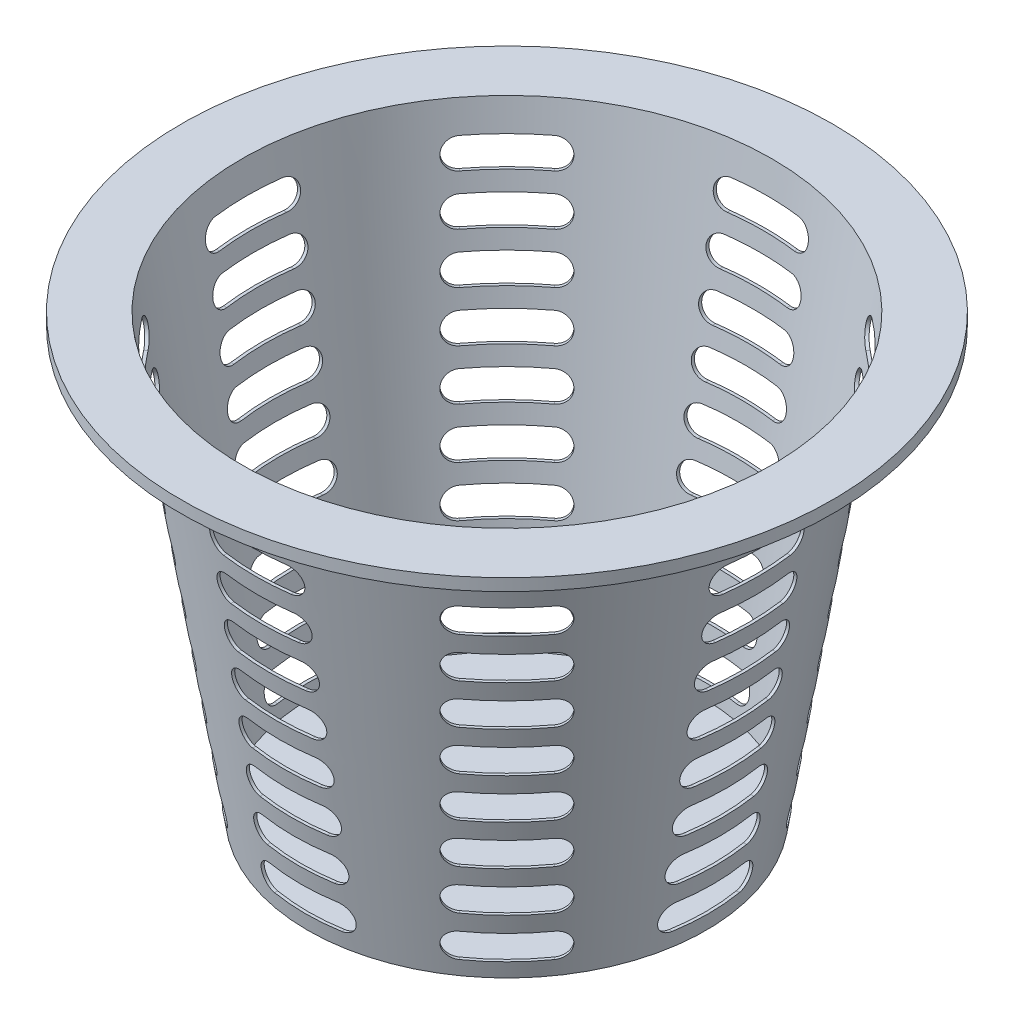
from build123d import *

# Parameters (mm, degrees)
THICKEN1_T2               = 2
CUT_EXTRUDE1_DEPTH        = 190
LPATTERN1_COUNT           = 9
LPATTERN1_PITCH           = 30
CIRPATTERN2_COUNT         = 8
CIRPATTERN2_COPY_1_DEPTH  = 190
CIRPATTERN2_COPY_2_DEPTH  = 190
CIRPATTERN2_COPY_3_DEPTH  = 190
CIRPATTERN2_COPY_4_DEPTH  = 190
CIRPATTERN2_COPY_5_DEPTH  = 190
CIRPATTERN2_COPY_6_DEPTH  = 190
CIRPATTERN2_COPY_7_DEPTH  = 190
CIRPATTERN2_COPY_8_DEPTH  = 190
CIRPATTERN2_COPY_9_DEPTH  = 190
CIRPATTERN2_COPY_10_DEPTH = 190
CIRPATTERN2_COPY_11_DEPTH = 190
CIRPATTERN2_COPY_12_DEPTH = 190
CIRPATTERN2_COPY_13_DEPTH = 190
CIRPATTERN2_COPY_14_DEPTH = 190
CIRPATTERN2_COPY_15_DEPTH = 190
CIRPATTERN2_COPY_16_DEPTH = 190
CIRPATTERN2_COPY_17_DEPTH = 190
CIRPATTERN2_COPY_18_DEPTH = 190
CIRPATTERN2_COPY_19_DEPTH = 190
CIRPATTERN2_COPY_20_DEPTH = 190
CIRPATTERN2_COPY_21_DEPTH = 190
CIRPATTERN2_COPY_22_DEPTH = 190
CIRPATTERN2_COPY_23_DEPTH = 190
CIRPATTERN2_COPY_24_DEPTH = 190
CIRPATTERN2_COPY_25_DEPTH = 190
CIRPATTERN2_COPY_26_DEPTH = 190
CIRPATTERN2_COPY_27_DEPTH = 190
CIRPATTERN2_COPY_28_DEPTH = 190
CIRPATTERN2_COPY_29_DEPTH = 190
CIRPATTERN2_COPY_30_DEPTH = 190
CIRPATTERN2_COPY_31_DEPTH = 190
CIRPATTERN2_COPY_32_DEPTH = 190
CIRPATTERN2_COPY_33_DEPTH = 190
CIRPATTERN2_COPY_34_DEPTH = 190
CIRPATTERN2_COPY_35_DEPTH = 190
CIRPATTERN2_COPY_36_DEPTH = 190
CIRPATTERN2_COPY_37_DEPTH = 190
CIRPATTERN2_COPY_38_DEPTH = 190
CIRPATTERN2_COPY_39_DEPTH = 190
CIRPATTERN2_COPY_40_DEPTH = 190
CIRPATTERN2_COPY_41_DEPTH = 190
CIRPATTERN2_COPY_42_DEPTH = 190
CIRPATTERN2_COPY_43_DEPTH = 190
CIRPATTERN2_COPY_44_DEPTH = 190
CIRPATTERN2_COPY_45_DEPTH = 190
CIRPATTERN2_COPY_46_DEPTH = 190
CIRPATTERN2_COPY_47_DEPTH = 190
CIRPATTERN2_COPY_48_DEPTH = 190
CIRPATTERN2_COPY_49_DEPTH = 190
CIRPATTERN2_COPY_50_DEPTH = 190
CIRPATTERN2_COPY_51_DEPTH = 190
CIRPATTERN2_COPY_52_DEPTH = 190
CIRPATTERN2_COPY_53_DEPTH = 190
CIRPATTERN2_COPY_54_DEPTH = 190
CIRPATTERN2_COPY_55_DEPTH = 190
CIRPATTERN2_COPY_56_DEPTH = 190


with BuildPart() as body_1:
    # Surface-Revolve1: a surface, the sketch's curves turned about an axis
    with BuildLine(Plane.XY, mode=Mode.PRIVATE) as surface_revolve1_1_path:
        Line((0, -120.209059233), (130, -120.209059233))
        Line((130, -120.209059233), (175.365994862, 166.220559539))
        Line((175.365994862, 166.220559539), (215.365994862, 166.220559539))
        Line((215.365994862, 166.220559539), (215.365994862, 158.220559539))
    surface_revolve1_1 = Shell.revolve(surface_revolve1_1_path.wire(), 360, Axis((0, 129.790940767, 0), (0, -1, 0)))
    add(Solid.thicken(surface_revolve1_1, -THICKEN1_T2))

    # Sketch2 → Cut-Extrude1 (cut)
    with BuildSketch(Plane.XY):
        with BuildLine():
            Line((22.22432483, -111.75560677), (-22.22432483, -111.75560677))
            ThreePointArc((-22.22432483, -111.75560677), (-31.363299527, -102.616632073), (-22.22432483, -93.477657376))
            Line((-22.22432483, -93.477657376), (22.22432483, -93.477657376))
            ThreePointArc((22.22432483, -93.477657376), (31.363299527, -102.616632073), (22.22432483, -111.75560677))
        make_face()
    cut_extrude1 = extrude(amount=-CUT_EXTRUDE1_DEPTH, mode=Mode.SUBTRACT)

    # LPattern1: Cut-Extrude1 ×9
    with Locations(*[(0, i * LPATTERN1_PITCH, 0) for i in range(1, LPATTERN1_COUNT)]):
        add(cut_extrude1, mode=Mode.SUBTRACT)

    # CirPattern2: Cut-Extrude1 ×8 about axis
    cirpattern2_axis = Axis((0, -120.521928164, 0), (0, 1, 0))
    for i in range(1, CIRPATTERN2_COUNT):
        add(cut_extrude1.rotate(cirpattern2_axis, i * 360 / CIRPATTERN2_COUNT), mode=Mode.SUBTRACT)

    # CirPattern2 copy 1 sketch → CirPattern2 copy 1 (cut)
    with BuildSketch(Plane(origin=(0, 30, 0), x_dir=(0.7071067811865476, 0, -0.7071067811865475), z_dir=(0.7071067811865475, 0, 0.7071067811865476))):
        with BuildLine():
            Line((22.22432483, -111.75560677), (-22.22432483, -111.75560677))
            ThreePointArc((-22.22432483, -111.75560677), (-31.363299527, -102.616632073), (-22.22432483, -93.477657376))
            Line((-22.22432483, -93.477657376), (22.22432483, -93.477657376))
            ThreePointArc((22.22432483, -93.477657376), (31.363299527, -102.616632073), (22.22432483, -111.75560677))
        make_face()
    extrude(amount=-CIRPATTERN2_COPY_1_DEPTH, mode=Mode.SUBTRACT)

    # CirPattern2 copy 2 sketch → CirPattern2 copy 2 (cut)
    with BuildSketch(Plane(origin=(0, 30, 0), x_dir=(0, 0, -1), z_dir=(1, 0, 0))):
        with BuildLine():
            Line((22.22432483, -111.75560677), (-22.22432483, -111.75560677))
            ThreePointArc((-22.22432483, -111.75560677), (-31.363299527, -102.616632073), (-22.22432483, -93.477657376))
            Line((-22.22432483, -93.477657376), (22.22432483, -93.477657376))
            ThreePointArc((22.22432483, -93.477657376), (31.363299527, -102.616632073), (22.22432483, -111.75560677))
        make_face()
    extrude(amount=-CIRPATTERN2_COPY_2_DEPTH, mode=Mode.SUBTRACT)

    # CirPattern2 copy 3 sketch → CirPattern2 copy 3 (cut)
    with BuildSketch(Plane(origin=(0, 30, 0), x_dir=(-0.7071067811865475, 0, -0.7071067811865476), z_dir=(0.7071067811865476, 0, -0.7071067811865475))):
        with BuildLine():
            Line((22.22432483, -111.75560677), (-22.22432483, -111.75560677))
            ThreePointArc((-22.22432483, -111.75560677), (-31.363299527, -102.616632073), (-22.22432483, -93.477657376))
            Line((-22.22432483, -93.477657376), (22.22432483, -93.477657376))
            ThreePointArc((22.22432483, -93.477657376), (31.363299527, -102.616632073), (22.22432483, -111.75560677))
        make_face()
    extrude(amount=-CIRPATTERN2_COPY_3_DEPTH, mode=Mode.SUBTRACT)

    # CirPattern2 copy 4 sketch → CirPattern2 copy 4 (cut)
    with BuildSketch(Plane(origin=(0, 30, 0), x_dir=(-1, 0, 0), z_dir=(0, 0, -1))):
        with BuildLine():
            Line((22.22432483, -111.75560677), (-22.22432483, -111.75560677))
            ThreePointArc((-22.22432483, -111.75560677), (-31.363299527, -102.616632073), (-22.22432483, -93.477657376))
            Line((-22.22432483, -93.477657376), (22.22432483, -93.477657376))
            ThreePointArc((22.22432483, -93.477657376), (31.363299527, -102.616632073), (22.22432483, -111.75560677))
        make_face()
    extrude(amount=-CIRPATTERN2_COPY_4_DEPTH, mode=Mode.SUBTRACT)

    # CirPattern2 copy 5 sketch → CirPattern2 copy 5 (cut)
    with BuildSketch(Plane(origin=(0, 30, 0), x_dir=(-0.7071067811865477, 0, 0.7071067811865475), z_dir=(-0.7071067811865475, 0, -0.7071067811865477))):
        with BuildLine():
            Line((22.22432483, -111.75560677), (-22.22432483, -111.75560677))
            ThreePointArc((-22.22432483, -111.75560677), (-31.363299527, -102.616632073), (-22.22432483, -93.477657376))
            Line((-22.22432483, -93.477657376), (22.22432483, -93.477657376))
            ThreePointArc((22.22432483, -93.477657376), (31.363299527, -102.616632073), (22.22432483, -111.75560677))
        make_face()
    extrude(amount=-CIRPATTERN2_COPY_5_DEPTH, mode=Mode.SUBTRACT)

    # CirPattern2 copy 6 sketch → CirPattern2 copy 6 (cut)
    with BuildSketch(Plane(origin=(0, 30, 0), x_dir=(0, 0, 1), z_dir=(-1, 0, 0))):
        with BuildLine():
            Line((22.22432483, -111.75560677), (-22.22432483, -111.75560677))
            ThreePointArc((-22.22432483, -111.75560677), (-31.363299527, -102.616632073), (-22.22432483, -93.477657376))
            Line((-22.22432483, -93.477657376), (22.22432483, -93.477657376))
            ThreePointArc((22.22432483, -93.477657376), (31.363299527, -102.616632073), (22.22432483, -111.75560677))
        make_face()
    extrude(amount=-CIRPATTERN2_COPY_6_DEPTH, mode=Mode.SUBTRACT)

    # CirPattern2 copy 7 sketch → CirPattern2 copy 7 (cut)
    with BuildSketch(Plane(origin=(0, 30, 0), x_dir=(0.7071067811865474, 0, 0.7071067811865477), z_dir=(-0.7071067811865477, 0, 0.7071067811865474))):
        with BuildLine():
            Line((22.22432483, -111.75560677), (-22.22432483, -111.75560677))
            ThreePointArc((-22.22432483, -111.75560677), (-31.363299527, -102.616632073), (-22.22432483, -93.477657376))
            Line((-22.22432483, -93.477657376), (22.22432483, -93.477657376))
            ThreePointArc((22.22432483, -93.477657376), (31.363299527, -102.616632073), (22.22432483, -111.75560677))
        make_face()
    extrude(amount=-CIRPATTERN2_COPY_7_DEPTH, mode=Mode.SUBTRACT)

    # CirPattern2 copy 8 sketch → CirPattern2 copy 8 (cut)
    with BuildSketch(Plane(origin=(0, 60, 0), x_dir=(0.7071067811865476, 0, -0.7071067811865475), z_dir=(0.7071067811865475, 0, 0.7071067811865476))):
        with BuildLine():
            Line((22.22432483, -111.75560677), (-22.22432483, -111.75560677))
            ThreePointArc((-22.22432483, -111.75560677), (-31.363299527, -102.616632073), (-22.22432483, -93.477657376))
            Line((-22.22432483, -93.477657376), (22.22432483, -93.477657376))
            ThreePointArc((22.22432483, -93.477657376), (31.363299527, -102.616632073), (22.22432483, -111.75560677))
        make_face()
    extrude(amount=-CIRPATTERN2_COPY_8_DEPTH, mode=Mode.SUBTRACT)

    # CirPattern2 copy 9 sketch → CirPattern2 copy 9 (cut)
    with BuildSketch(Plane(origin=(0, 60, 0), x_dir=(0, 0, -1), z_dir=(1, 0, 0))):
        with BuildLine():
            Line((22.22432483, -111.75560677), (-22.22432483, -111.75560677))
            ThreePointArc((-22.22432483, -111.75560677), (-31.363299527, -102.616632073), (-22.22432483, -93.477657376))
            Line((-22.22432483, -93.477657376), (22.22432483, -93.477657376))
            ThreePointArc((22.22432483, -93.477657376), (31.363299527, -102.616632073), (22.22432483, -111.75560677))
        make_face()
    extrude(amount=-CIRPATTERN2_COPY_9_DEPTH, mode=Mode.SUBTRACT)

    # CirPattern2 copy 10 sketch → CirPattern2 copy 10 (cut)
    with BuildSketch(Plane(origin=(0, 60, 0), x_dir=(-0.7071067811865475, 0, -0.7071067811865476), z_dir=(0.7071067811865476, 0, -0.7071067811865475))):
        with BuildLine():
            Line((22.22432483, -111.75560677), (-22.22432483, -111.75560677))
            ThreePointArc((-22.22432483, -111.75560677), (-31.363299527, -102.616632073), (-22.22432483, -93.477657376))
            Line((-22.22432483, -93.477657376), (22.22432483, -93.477657376))
            ThreePointArc((22.22432483, -93.477657376), (31.363299527, -102.616632073), (22.22432483, -111.75560677))
        make_face()
    extrude(amount=-CIRPATTERN2_COPY_10_DEPTH, mode=Mode.SUBTRACT)

    # CirPattern2 copy 11 sketch → CirPattern2 copy 11 (cut)
    with BuildSketch(Plane(origin=(0, 60, 0), x_dir=(-1, 0, 0), z_dir=(0, 0, -1))):
        with BuildLine():
            Line((22.22432483, -111.75560677), (-22.22432483, -111.75560677))
            ThreePointArc((-22.22432483, -111.75560677), (-31.363299527, -102.616632073), (-22.22432483, -93.477657376))
            Line((-22.22432483, -93.477657376), (22.22432483, -93.477657376))
            ThreePointArc((22.22432483, -93.477657376), (31.363299527, -102.616632073), (22.22432483, -111.75560677))
        make_face()
    extrude(amount=-CIRPATTERN2_COPY_11_DEPTH, mode=Mode.SUBTRACT)

    # CirPattern2 copy 12 sketch → CirPattern2 copy 12 (cut)
    with BuildSketch(Plane(origin=(0, 60, 0), x_dir=(-0.7071067811865477, 0, 0.7071067811865475), z_dir=(-0.7071067811865475, 0, -0.7071067811865477))):
        with BuildLine():
            Line((22.22432483, -111.75560677), (-22.22432483, -111.75560677))
            ThreePointArc((-22.22432483, -111.75560677), (-31.363299527, -102.616632073), (-22.22432483, -93.477657376))
            Line((-22.22432483, -93.477657376), (22.22432483, -93.477657376))
            ThreePointArc((22.22432483, -93.477657376), (31.363299527, -102.616632073), (22.22432483, -111.75560677))
        make_face()
    extrude(amount=-CIRPATTERN2_COPY_12_DEPTH, mode=Mode.SUBTRACT)

    # CirPattern2 copy 13 sketch → CirPattern2 copy 13 (cut)
    with BuildSketch(Plane(origin=(0, 60, 0), x_dir=(0, 0, 1), z_dir=(-1, 0, 0))):
        with BuildLine():
            Line((22.22432483, -111.75560677), (-22.22432483, -111.75560677))
            ThreePointArc((-22.22432483, -111.75560677), (-31.363299527, -102.616632073), (-22.22432483, -93.477657376))
            Line((-22.22432483, -93.477657376), (22.22432483, -93.477657376))
            ThreePointArc((22.22432483, -93.477657376), (31.363299527, -102.616632073), (22.22432483, -111.75560677))
        make_face()
    extrude(amount=-CIRPATTERN2_COPY_13_DEPTH, mode=Mode.SUBTRACT)

    # CirPattern2 copy 14 sketch → CirPattern2 copy 14 (cut)
    with BuildSketch(Plane(origin=(0, 60, 0), x_dir=(0.7071067811865474, 0, 0.7071067811865477), z_dir=(-0.7071067811865477, 0, 0.7071067811865474))):
        with BuildLine():
            Line((22.22432483, -111.75560677), (-22.22432483, -111.75560677))
            ThreePointArc((-22.22432483, -111.75560677), (-31.363299527, -102.616632073), (-22.22432483, -93.477657376))
            Line((-22.22432483, -93.477657376), (22.22432483, -93.477657376))
            ThreePointArc((22.22432483, -93.477657376), (31.363299527, -102.616632073), (22.22432483, -111.75560677))
        make_face()
    extrude(amount=-CIRPATTERN2_COPY_14_DEPTH, mode=Mode.SUBTRACT)

    # CirPattern2 copy 15 sketch → CirPattern2 copy 15 (cut)
    with BuildSketch(Plane(origin=(0, 90, 0), x_dir=(0.7071067811865476, 0, -0.7071067811865475), z_dir=(0.7071067811865475, 0, 0.7071067811865476))):
        with BuildLine():
            Line((22.22432483, -111.75560677), (-22.22432483, -111.75560677))
            ThreePointArc((-22.22432483, -111.75560677), (-31.363299527, -102.616632073), (-22.22432483, -93.477657376))
            Line((-22.22432483, -93.477657376), (22.22432483, -93.477657376))
            ThreePointArc((22.22432483, -93.477657376), (31.363299527, -102.616632073), (22.22432483, -111.75560677))
        make_face()
    extrude(amount=-CIRPATTERN2_COPY_15_DEPTH, mode=Mode.SUBTRACT)

    # CirPattern2 copy 16 sketch → CirPattern2 copy 16 (cut)
    with BuildSketch(Plane(origin=(0, 90, 0), x_dir=(0, 0, -1), z_dir=(1, 0, 0))):
        with BuildLine():
            Line((22.22432483, -111.75560677), (-22.22432483, -111.75560677))
            ThreePointArc((-22.22432483, -111.75560677), (-31.363299527, -102.616632073), (-22.22432483, -93.477657376))
            Line((-22.22432483, -93.477657376), (22.22432483, -93.477657376))
            ThreePointArc((22.22432483, -93.477657376), (31.363299527, -102.616632073), (22.22432483, -111.75560677))
        make_face()
    extrude(amount=-CIRPATTERN2_COPY_16_DEPTH, mode=Mode.SUBTRACT)

    # CirPattern2 copy 17 sketch → CirPattern2 copy 17 (cut)
    with BuildSketch(Plane(origin=(0, 90, 0), x_dir=(-0.7071067811865475, 0, -0.7071067811865476), z_dir=(0.7071067811865476, 0, -0.7071067811865475))):
        with BuildLine():
            Line((22.22432483, -111.75560677), (-22.22432483, -111.75560677))
            ThreePointArc((-22.22432483, -111.75560677), (-31.363299527, -102.616632073), (-22.22432483, -93.477657376))
            Line((-22.22432483, -93.477657376), (22.22432483, -93.477657376))
            ThreePointArc((22.22432483, -93.477657376), (31.363299527, -102.616632073), (22.22432483, -111.75560677))
        make_face()
    extrude(amount=-CIRPATTERN2_COPY_17_DEPTH, mode=Mode.SUBTRACT)

    # CirPattern2 copy 18 sketch → CirPattern2 copy 18 (cut)
    with BuildSketch(Plane(origin=(0, 90, 0), x_dir=(-1, 0, 0), z_dir=(0, 0, -1))):
        with BuildLine():
            Line((22.22432483, -111.75560677), (-22.22432483, -111.75560677))
            ThreePointArc((-22.22432483, -111.75560677), (-31.363299527, -102.616632073), (-22.22432483, -93.477657376))
            Line((-22.22432483, -93.477657376), (22.22432483, -93.477657376))
            ThreePointArc((22.22432483, -93.477657376), (31.363299527, -102.616632073), (22.22432483, -111.75560677))
        make_face()
    extrude(amount=-CIRPATTERN2_COPY_18_DEPTH, mode=Mode.SUBTRACT)

    # CirPattern2 copy 19 sketch → CirPattern2 copy 19 (cut)
    with BuildSketch(Plane(origin=(0, 90, 0), x_dir=(-0.7071067811865477, 0, 0.7071067811865475), z_dir=(-0.7071067811865475, 0, -0.7071067811865477))):
        with BuildLine():
            Line((22.22432483, -111.75560677), (-22.22432483, -111.75560677))
            ThreePointArc((-22.22432483, -111.75560677), (-31.363299527, -102.616632073), (-22.22432483, -93.477657376))
            Line((-22.22432483, -93.477657376), (22.22432483, -93.477657376))
            ThreePointArc((22.22432483, -93.477657376), (31.363299527, -102.616632073), (22.22432483, -111.75560677))
        make_face()
    extrude(amount=-CIRPATTERN2_COPY_19_DEPTH, mode=Mode.SUBTRACT)

    # CirPattern2 copy 20 sketch → CirPattern2 copy 20 (cut)
    with BuildSketch(Plane(origin=(0, 90, 0), x_dir=(0, 0, 1), z_dir=(-1, 0, 0))):
        with BuildLine():
            Line((22.22432483, -111.75560677), (-22.22432483, -111.75560677))
            ThreePointArc((-22.22432483, -111.75560677), (-31.363299527, -102.616632073), (-22.22432483, -93.477657376))
            Line((-22.22432483, -93.477657376), (22.22432483, -93.477657376))
            ThreePointArc((22.22432483, -93.477657376), (31.363299527, -102.616632073), (22.22432483, -111.75560677))
        make_face()
    extrude(amount=-CIRPATTERN2_COPY_20_DEPTH, mode=Mode.SUBTRACT)

    # CirPattern2 copy 21 sketch → CirPattern2 copy 21 (cut)
    with BuildSketch(Plane(origin=(0, 90, 0), x_dir=(0.7071067811865474, 0, 0.7071067811865477), z_dir=(-0.7071067811865477, 0, 0.7071067811865474))):
        with BuildLine():
            Line((22.22432483, -111.75560677), (-22.22432483, -111.75560677))
            ThreePointArc((-22.22432483, -111.75560677), (-31.363299527, -102.616632073), (-22.22432483, -93.477657376))
            Line((-22.22432483, -93.477657376), (22.22432483, -93.477657376))
            ThreePointArc((22.22432483, -93.477657376), (31.363299527, -102.616632073), (22.22432483, -111.75560677))
        make_face()
    extrude(amount=-CIRPATTERN2_COPY_21_DEPTH, mode=Mode.SUBTRACT)

    # CirPattern2 copy 22 sketch → CirPattern2 copy 22 (cut)
    with BuildSketch(Plane(origin=(0, 120, 0), x_dir=(0.7071067811865476, 0, -0.7071067811865475), z_dir=(0.7071067811865475, 0, 0.7071067811865476))):
        with BuildLine():
            Line((22.22432483, -111.75560677), (-22.22432483, -111.75560677))
            ThreePointArc((-22.22432483, -111.75560677), (-31.363299527, -102.616632073), (-22.22432483, -93.477657376))
            Line((-22.22432483, -93.477657376), (22.22432483, -93.477657376))
            ThreePointArc((22.22432483, -93.477657376), (31.363299527, -102.616632073), (22.22432483, -111.75560677))
        make_face()
    extrude(amount=-CIRPATTERN2_COPY_22_DEPTH, mode=Mode.SUBTRACT)

    # CirPattern2 copy 23 sketch → CirPattern2 copy 23 (cut)
    with BuildSketch(Plane(origin=(0, 120, 0), x_dir=(0, 0, -1), z_dir=(1, 0, 0))):
        with BuildLine():
            Line((22.22432483, -111.75560677), (-22.22432483, -111.75560677))
            ThreePointArc((-22.22432483, -111.75560677), (-31.363299527, -102.616632073), (-22.22432483, -93.477657376))
            Line((-22.22432483, -93.477657376), (22.22432483, -93.477657376))
            ThreePointArc((22.22432483, -93.477657376), (31.363299527, -102.616632073), (22.22432483, -111.75560677))
        make_face()
    extrude(amount=-CIRPATTERN2_COPY_23_DEPTH, mode=Mode.SUBTRACT)

    # CirPattern2 copy 24 sketch → CirPattern2 copy 24 (cut)
    with BuildSketch(Plane(origin=(0, 120, 0), x_dir=(-0.7071067811865475, 0, -0.7071067811865476), z_dir=(0.7071067811865476, 0, -0.7071067811865475))):
        with BuildLine():
            Line((22.22432483, -111.75560677), (-22.22432483, -111.75560677))
            ThreePointArc((-22.22432483, -111.75560677), (-31.363299527, -102.616632073), (-22.22432483, -93.477657376))
            Line((-22.22432483, -93.477657376), (22.22432483, -93.477657376))
            ThreePointArc((22.22432483, -93.477657376), (31.363299527, -102.616632073), (22.22432483, -111.75560677))
        make_face()
    extrude(amount=-CIRPATTERN2_COPY_24_DEPTH, mode=Mode.SUBTRACT)

    # CirPattern2 copy 25 sketch → CirPattern2 copy 25 (cut)
    with BuildSketch(Plane(origin=(0, 120, 0), x_dir=(-1, 0, 0), z_dir=(0, 0, -1))):
        with BuildLine():
            Line((22.22432483, -111.75560677), (-22.22432483, -111.75560677))
            ThreePointArc((-22.22432483, -111.75560677), (-31.363299527, -102.616632073), (-22.22432483, -93.477657376))
            Line((-22.22432483, -93.477657376), (22.22432483, -93.477657376))
            ThreePointArc((22.22432483, -93.477657376), (31.363299527, -102.616632073), (22.22432483, -111.75560677))
        make_face()
    extrude(amount=-CIRPATTERN2_COPY_25_DEPTH, mode=Mode.SUBTRACT)

    # CirPattern2 copy 26 sketch → CirPattern2 copy 26 (cut)
    with BuildSketch(Plane(origin=(0, 120, 0), x_dir=(-0.7071067811865477, 0, 0.7071067811865475), z_dir=(-0.7071067811865475, 0, -0.7071067811865477))):
        with BuildLine():
            Line((22.22432483, -111.75560677), (-22.22432483, -111.75560677))
            ThreePointArc((-22.22432483, -111.75560677), (-31.363299527, -102.616632073), (-22.22432483, -93.477657376))
            Line((-22.22432483, -93.477657376), (22.22432483, -93.477657376))
            ThreePointArc((22.22432483, -93.477657376), (31.363299527, -102.616632073), (22.22432483, -111.75560677))
        make_face()
    extrude(amount=-CIRPATTERN2_COPY_26_DEPTH, mode=Mode.SUBTRACT)

    # CirPattern2 copy 27 sketch → CirPattern2 copy 27 (cut)
    with BuildSketch(Plane(origin=(0, 120, 0), x_dir=(0, 0, 1), z_dir=(-1, 0, 0))):
        with BuildLine():
            Line((22.22432483, -111.75560677), (-22.22432483, -111.75560677))
            ThreePointArc((-22.22432483, -111.75560677), (-31.363299527, -102.616632073), (-22.22432483, -93.477657376))
            Line((-22.22432483, -93.477657376), (22.22432483, -93.477657376))
            ThreePointArc((22.22432483, -93.477657376), (31.363299527, -102.616632073), (22.22432483, -111.75560677))
        make_face()
    extrude(amount=-CIRPATTERN2_COPY_27_DEPTH, mode=Mode.SUBTRACT)

    # CirPattern2 copy 28 sketch → CirPattern2 copy 28 (cut)
    with BuildSketch(Plane(origin=(0, 120, 0), x_dir=(0.7071067811865474, 0, 0.7071067811865477), z_dir=(-0.7071067811865477, 0, 0.7071067811865474))):
        with BuildLine():
            Line((22.22432483, -111.75560677), (-22.22432483, -111.75560677))
            ThreePointArc((-22.22432483, -111.75560677), (-31.363299527, -102.616632073), (-22.22432483, -93.477657376))
            Line((-22.22432483, -93.477657376), (22.22432483, -93.477657376))
            ThreePointArc((22.22432483, -93.477657376), (31.363299527, -102.616632073), (22.22432483, -111.75560677))
        make_face()
    extrude(amount=-CIRPATTERN2_COPY_28_DEPTH, mode=Mode.SUBTRACT)

    # CirPattern2 copy 29 sketch → CirPattern2 copy 29 (cut)
    with BuildSketch(Plane(origin=(0, 150, 0), x_dir=(0.7071067811865476, 0, -0.7071067811865475), z_dir=(0.7071067811865475, 0, 0.7071067811865476))):
        with BuildLine():
            Line((22.22432483, -111.75560677), (-22.22432483, -111.75560677))
            ThreePointArc((-22.22432483, -111.75560677), (-31.363299527, -102.616632073), (-22.22432483, -93.477657376))
            Line((-22.22432483, -93.477657376), (22.22432483, -93.477657376))
            ThreePointArc((22.22432483, -93.477657376), (31.363299527, -102.616632073), (22.22432483, -111.75560677))
        make_face()
    extrude(amount=-CIRPATTERN2_COPY_29_DEPTH, mode=Mode.SUBTRACT)

    # CirPattern2 copy 30 sketch → CirPattern2 copy 30 (cut)
    with BuildSketch(Plane(origin=(0, 150, 0), x_dir=(0, 0, -1), z_dir=(1, 0, 0))):
        with BuildLine():
            Line((22.22432483, -111.75560677), (-22.22432483, -111.75560677))
            ThreePointArc((-22.22432483, -111.75560677), (-31.363299527, -102.616632073), (-22.22432483, -93.477657376))
            Line((-22.22432483, -93.477657376), (22.22432483, -93.477657376))
            ThreePointArc((22.22432483, -93.477657376), (31.363299527, -102.616632073), (22.22432483, -111.75560677))
        make_face()
    extrude(amount=-CIRPATTERN2_COPY_30_DEPTH, mode=Mode.SUBTRACT)

    # CirPattern2 copy 31 sketch → CirPattern2 copy 31 (cut)
    with BuildSketch(Plane(origin=(0, 150, 0), x_dir=(-0.7071067811865475, 0, -0.7071067811865476), z_dir=(0.7071067811865476, 0, -0.7071067811865475))):
        with BuildLine():
            Line((22.22432483, -111.75560677), (-22.22432483, -111.75560677))
            ThreePointArc((-22.22432483, -111.75560677), (-31.363299527, -102.616632073), (-22.22432483, -93.477657376))
            Line((-22.22432483, -93.477657376), (22.22432483, -93.477657376))
            ThreePointArc((22.22432483, -93.477657376), (31.363299527, -102.616632073), (22.22432483, -111.75560677))
        make_face()
    extrude(amount=-CIRPATTERN2_COPY_31_DEPTH, mode=Mode.SUBTRACT)

    # CirPattern2 copy 32 sketch → CirPattern2 copy 32 (cut)
    with BuildSketch(Plane(origin=(0, 150, 0), x_dir=(-1, 0, 0), z_dir=(0, 0, -1))):
        with BuildLine():
            Line((22.22432483, -111.75560677), (-22.22432483, -111.75560677))
            ThreePointArc((-22.22432483, -111.75560677), (-31.363299527, -102.616632073), (-22.22432483, -93.477657376))
            Line((-22.22432483, -93.477657376), (22.22432483, -93.477657376))
            ThreePointArc((22.22432483, -93.477657376), (31.363299527, -102.616632073), (22.22432483, -111.75560677))
        make_face()
    extrude(amount=-CIRPATTERN2_COPY_32_DEPTH, mode=Mode.SUBTRACT)

    # CirPattern2 copy 33 sketch → CirPattern2 copy 33 (cut)
    with BuildSketch(Plane(origin=(0, 150, 0), x_dir=(-0.7071067811865477, 0, 0.7071067811865475), z_dir=(-0.7071067811865475, 0, -0.7071067811865477))):
        with BuildLine():
            Line((22.22432483, -111.75560677), (-22.22432483, -111.75560677))
            ThreePointArc((-22.22432483, -111.75560677), (-31.363299527, -102.616632073), (-22.22432483, -93.477657376))
            Line((-22.22432483, -93.477657376), (22.22432483, -93.477657376))
            ThreePointArc((22.22432483, -93.477657376), (31.363299527, -102.616632073), (22.22432483, -111.75560677))
        make_face()
    extrude(amount=-CIRPATTERN2_COPY_33_DEPTH, mode=Mode.SUBTRACT)

    # CirPattern2 copy 34 sketch → CirPattern2 copy 34 (cut)
    with BuildSketch(Plane(origin=(0, 150, 0), x_dir=(0, 0, 1), z_dir=(-1, 0, 0))):
        with BuildLine():
            Line((22.22432483, -111.75560677), (-22.22432483, -111.75560677))
            ThreePointArc((-22.22432483, -111.75560677), (-31.363299527, -102.616632073), (-22.22432483, -93.477657376))
            Line((-22.22432483, -93.477657376), (22.22432483, -93.477657376))
            ThreePointArc((22.22432483, -93.477657376), (31.363299527, -102.616632073), (22.22432483, -111.75560677))
        make_face()
    extrude(amount=-CIRPATTERN2_COPY_34_DEPTH, mode=Mode.SUBTRACT)

    # CirPattern2 copy 35 sketch → CirPattern2 copy 35 (cut)
    with BuildSketch(Plane(origin=(0, 150, 0), x_dir=(0.7071067811865474, 0, 0.7071067811865477), z_dir=(-0.7071067811865477, 0, 0.7071067811865474))):
        with BuildLine():
            Line((22.22432483, -111.75560677), (-22.22432483, -111.75560677))
            ThreePointArc((-22.22432483, -111.75560677), (-31.363299527, -102.616632073), (-22.22432483, -93.477657376))
            Line((-22.22432483, -93.477657376), (22.22432483, -93.477657376))
            ThreePointArc((22.22432483, -93.477657376), (31.363299527, -102.616632073), (22.22432483, -111.75560677))
        make_face()
    extrude(amount=-CIRPATTERN2_COPY_35_DEPTH, mode=Mode.SUBTRACT)

    # CirPattern2 copy 36 sketch → CirPattern2 copy 36 (cut)
    with BuildSketch(Plane(origin=(0, 180, 0), x_dir=(0.7071067811865476, 0, -0.7071067811865475), z_dir=(0.7071067811865475, 0, 0.7071067811865476))):
        with BuildLine():
            Line((22.22432483, -111.75560677), (-22.22432483, -111.75560677))
            ThreePointArc((-22.22432483, -111.75560677), (-31.363299527, -102.616632073), (-22.22432483, -93.477657376))
            Line((-22.22432483, -93.477657376), (22.22432483, -93.477657376))
            ThreePointArc((22.22432483, -93.477657376), (31.363299527, -102.616632073), (22.22432483, -111.75560677))
        make_face()
    extrude(amount=-CIRPATTERN2_COPY_36_DEPTH, mode=Mode.SUBTRACT)

    # CirPattern2 copy 37 sketch → CirPattern2 copy 37 (cut)
    with BuildSketch(Plane(origin=(0, 180, 0), x_dir=(0, 0, -1), z_dir=(1, 0, 0))):
        with BuildLine():
            Line((22.22432483, -111.75560677), (-22.22432483, -111.75560677))
            ThreePointArc((-22.22432483, -111.75560677), (-31.363299527, -102.616632073), (-22.22432483, -93.477657376))
            Line((-22.22432483, -93.477657376), (22.22432483, -93.477657376))
            ThreePointArc((22.22432483, -93.477657376), (31.363299527, -102.616632073), (22.22432483, -111.75560677))
        make_face()
    extrude(amount=-CIRPATTERN2_COPY_37_DEPTH, mode=Mode.SUBTRACT)

    # CirPattern2 copy 38 sketch → CirPattern2 copy 38 (cut)
    with BuildSketch(Plane(origin=(0, 180, 0), x_dir=(-0.7071067811865475, 0, -0.7071067811865476), z_dir=(0.7071067811865476, 0, -0.7071067811865475))):
        with BuildLine():
            Line((22.22432483, -111.75560677), (-22.22432483, -111.75560677))
            ThreePointArc((-22.22432483, -111.75560677), (-31.363299527, -102.616632073), (-22.22432483, -93.477657376))
            Line((-22.22432483, -93.477657376), (22.22432483, -93.477657376))
            ThreePointArc((22.22432483, -93.477657376), (31.363299527, -102.616632073), (22.22432483, -111.75560677))
        make_face()
    extrude(amount=-CIRPATTERN2_COPY_38_DEPTH, mode=Mode.SUBTRACT)

    # CirPattern2 copy 39 sketch → CirPattern2 copy 39 (cut)
    with BuildSketch(Plane(origin=(0, 180, 0), x_dir=(-1, 0, 0), z_dir=(0, 0, -1))):
        with BuildLine():
            Line((22.22432483, -111.75560677), (-22.22432483, -111.75560677))
            ThreePointArc((-22.22432483, -111.75560677), (-31.363299527, -102.616632073), (-22.22432483, -93.477657376))
            Line((-22.22432483, -93.477657376), (22.22432483, -93.477657376))
            ThreePointArc((22.22432483, -93.477657376), (31.363299527, -102.616632073), (22.22432483, -111.75560677))
        make_face()
    extrude(amount=-CIRPATTERN2_COPY_39_DEPTH, mode=Mode.SUBTRACT)

    # CirPattern2 copy 40 sketch → CirPattern2 copy 40 (cut)
    with BuildSketch(Plane(origin=(0, 180, 0), x_dir=(-0.7071067811865477, 0, 0.7071067811865475), z_dir=(-0.7071067811865475, 0, -0.7071067811865477))):
        with BuildLine():
            Line((22.22432483, -111.75560677), (-22.22432483, -111.75560677))
            ThreePointArc((-22.22432483, -111.75560677), (-31.363299527, -102.616632073), (-22.22432483, -93.477657376))
            Line((-22.22432483, -93.477657376), (22.22432483, -93.477657376))
            ThreePointArc((22.22432483, -93.477657376), (31.363299527, -102.616632073), (22.22432483, -111.75560677))
        make_face()
    extrude(amount=-CIRPATTERN2_COPY_40_DEPTH, mode=Mode.SUBTRACT)

    # CirPattern2 copy 41 sketch → CirPattern2 copy 41 (cut)
    with BuildSketch(Plane(origin=(0, 180, 0), x_dir=(0, 0, 1), z_dir=(-1, 0, 0))):
        with BuildLine():
            Line((22.22432483, -111.75560677), (-22.22432483, -111.75560677))
            ThreePointArc((-22.22432483, -111.75560677), (-31.363299527, -102.616632073), (-22.22432483, -93.477657376))
            Line((-22.22432483, -93.477657376), (22.22432483, -93.477657376))
            ThreePointArc((22.22432483, -93.477657376), (31.363299527, -102.616632073), (22.22432483, -111.75560677))
        make_face()
    extrude(amount=-CIRPATTERN2_COPY_41_DEPTH, mode=Mode.SUBTRACT)

    # CirPattern2 copy 42 sketch → CirPattern2 copy 42 (cut)
    with BuildSketch(Plane(origin=(0, 180, 0), x_dir=(0.7071067811865474, 0, 0.7071067811865477), z_dir=(-0.7071067811865477, 0, 0.7071067811865474))):
        with BuildLine():
            Line((22.22432483, -111.75560677), (-22.22432483, -111.75560677))
            ThreePointArc((-22.22432483, -111.75560677), (-31.363299527, -102.616632073), (-22.22432483, -93.477657376))
            Line((-22.22432483, -93.477657376), (22.22432483, -93.477657376))
            ThreePointArc((22.22432483, -93.477657376), (31.363299527, -102.616632073), (22.22432483, -111.75560677))
        make_face()
    extrude(amount=-CIRPATTERN2_COPY_42_DEPTH, mode=Mode.SUBTRACT)

    # CirPattern2 copy 43 sketch → CirPattern2 copy 43 (cut)
    with BuildSketch(Plane(origin=(0, 210, 0), x_dir=(0.7071067811865476, 0, -0.7071067811865475), z_dir=(0.7071067811865475, 0, 0.7071067811865476))):
        with BuildLine():
            Line((22.22432483, -111.75560677), (-22.22432483, -111.75560677))
            ThreePointArc((-22.22432483, -111.75560677), (-31.363299527, -102.616632073), (-22.22432483, -93.477657376))
            Line((-22.22432483, -93.477657376), (22.22432483, -93.477657376))
            ThreePointArc((22.22432483, -93.477657376), (31.363299527, -102.616632073), (22.22432483, -111.75560677))
        make_face()
    extrude(amount=-CIRPATTERN2_COPY_43_DEPTH, mode=Mode.SUBTRACT)

    # CirPattern2 copy 44 sketch → CirPattern2 copy 44 (cut)
    with BuildSketch(Plane(origin=(0, 210, 0), x_dir=(0, 0, -1), z_dir=(1, 0, 0))):
        with BuildLine():
            Line((22.22432483, -111.75560677), (-22.22432483, -111.75560677))
            ThreePointArc((-22.22432483, -111.75560677), (-31.363299527, -102.616632073), (-22.22432483, -93.477657376))
            Line((-22.22432483, -93.477657376), (22.22432483, -93.477657376))
            ThreePointArc((22.22432483, -93.477657376), (31.363299527, -102.616632073), (22.22432483, -111.75560677))
        make_face()
    extrude(amount=-CIRPATTERN2_COPY_44_DEPTH, mode=Mode.SUBTRACT)

    # CirPattern2 copy 45 sketch → CirPattern2 copy 45 (cut)
    with BuildSketch(Plane(origin=(0, 210, 0), x_dir=(-0.7071067811865475, 0, -0.7071067811865476), z_dir=(0.7071067811865476, 0, -0.7071067811865475))):
        with BuildLine():
            Line((22.22432483, -111.75560677), (-22.22432483, -111.75560677))
            ThreePointArc((-22.22432483, -111.75560677), (-31.363299527, -102.616632073), (-22.22432483, -93.477657376))
            Line((-22.22432483, -93.477657376), (22.22432483, -93.477657376))
            ThreePointArc((22.22432483, -93.477657376), (31.363299527, -102.616632073), (22.22432483, -111.75560677))
        make_face()
    extrude(amount=-CIRPATTERN2_COPY_45_DEPTH, mode=Mode.SUBTRACT)

    # CirPattern2 copy 46 sketch → CirPattern2 copy 46 (cut)
    with BuildSketch(Plane(origin=(0, 210, 0), x_dir=(-1, 0, 0), z_dir=(0, 0, -1))):
        with BuildLine():
            Line((22.22432483, -111.75560677), (-22.22432483, -111.75560677))
            ThreePointArc((-22.22432483, -111.75560677), (-31.363299527, -102.616632073), (-22.22432483, -93.477657376))
            Line((-22.22432483, -93.477657376), (22.22432483, -93.477657376))
            ThreePointArc((22.22432483, -93.477657376), (31.363299527, -102.616632073), (22.22432483, -111.75560677))
        make_face()
    extrude(amount=-CIRPATTERN2_COPY_46_DEPTH, mode=Mode.SUBTRACT)

    # CirPattern2 copy 47 sketch → CirPattern2 copy 47 (cut)
    with BuildSketch(Plane(origin=(0, 210, 0), x_dir=(-0.7071067811865477, 0, 0.7071067811865475), z_dir=(-0.7071067811865475, 0, -0.7071067811865477))):
        with BuildLine():
            Line((22.22432483, -111.75560677), (-22.22432483, -111.75560677))
            ThreePointArc((-22.22432483, -111.75560677), (-31.363299527, -102.616632073), (-22.22432483, -93.477657376))
            Line((-22.22432483, -93.477657376), (22.22432483, -93.477657376))
            ThreePointArc((22.22432483, -93.477657376), (31.363299527, -102.616632073), (22.22432483, -111.75560677))
        make_face()
    extrude(amount=-CIRPATTERN2_COPY_47_DEPTH, mode=Mode.SUBTRACT)

    # CirPattern2 copy 48 sketch → CirPattern2 copy 48 (cut)
    with BuildSketch(Plane(origin=(0, 210, 0), x_dir=(0, 0, 1), z_dir=(-1, 0, 0))):
        with BuildLine():
            Line((22.22432483, -111.75560677), (-22.22432483, -111.75560677))
            ThreePointArc((-22.22432483, -111.75560677), (-31.363299527, -102.616632073), (-22.22432483, -93.477657376))
            Line((-22.22432483, -93.477657376), (22.22432483, -93.477657376))
            ThreePointArc((22.22432483, -93.477657376), (31.363299527, -102.616632073), (22.22432483, -111.75560677))
        make_face()
    extrude(amount=-CIRPATTERN2_COPY_48_DEPTH, mode=Mode.SUBTRACT)

    # CirPattern2 copy 49 sketch → CirPattern2 copy 49 (cut)
    with BuildSketch(Plane(origin=(0, 210, 0), x_dir=(0.7071067811865474, 0, 0.7071067811865477), z_dir=(-0.7071067811865477, 0, 0.7071067811865474))):
        with BuildLine():
            Line((22.22432483, -111.75560677), (-22.22432483, -111.75560677))
            ThreePointArc((-22.22432483, -111.75560677), (-31.363299527, -102.616632073), (-22.22432483, -93.477657376))
            Line((-22.22432483, -93.477657376), (22.22432483, -93.477657376))
            ThreePointArc((22.22432483, -93.477657376), (31.363299527, -102.616632073), (22.22432483, -111.75560677))
        make_face()
    extrude(amount=-CIRPATTERN2_COPY_49_DEPTH, mode=Mode.SUBTRACT)

    # CirPattern2 copy 50 sketch → CirPattern2 copy 50 (cut)
    with BuildSketch(Plane(origin=(0, 240, 0), x_dir=(0.7071067811865476, 0, -0.7071067811865475), z_dir=(0.7071067811865475, 0, 0.7071067811865476))):
        with BuildLine():
            Line((22.22432483, -111.75560677), (-22.22432483, -111.75560677))
            ThreePointArc((-22.22432483, -111.75560677), (-31.363299527, -102.616632073), (-22.22432483, -93.477657376))
            Line((-22.22432483, -93.477657376), (22.22432483, -93.477657376))
            ThreePointArc((22.22432483, -93.477657376), (31.363299527, -102.616632073), (22.22432483, -111.75560677))
        make_face()
    extrude(amount=-CIRPATTERN2_COPY_50_DEPTH, mode=Mode.SUBTRACT)

    # CirPattern2 copy 51 sketch → CirPattern2 copy 51 (cut)
    with BuildSketch(Plane(origin=(0, 240, 0), x_dir=(0, 0, -1), z_dir=(1, 0, 0))):
        with BuildLine():
            Line((22.22432483, -111.75560677), (-22.22432483, -111.75560677))
            ThreePointArc((-22.22432483, -111.75560677), (-31.363299527, -102.616632073), (-22.22432483, -93.477657376))
            Line((-22.22432483, -93.477657376), (22.22432483, -93.477657376))
            ThreePointArc((22.22432483, -93.477657376), (31.363299527, -102.616632073), (22.22432483, -111.75560677))
        make_face()
    extrude(amount=-CIRPATTERN2_COPY_51_DEPTH, mode=Mode.SUBTRACT)

    # CirPattern2 copy 52 sketch → CirPattern2 copy 52 (cut)
    with BuildSketch(Plane(origin=(0, 240, 0), x_dir=(-0.7071067811865475, 0, -0.7071067811865476), z_dir=(0.7071067811865476, 0, -0.7071067811865475))):
        with BuildLine():
            Line((22.22432483, -111.75560677), (-22.22432483, -111.75560677))
            ThreePointArc((-22.22432483, -111.75560677), (-31.363299527, -102.616632073), (-22.22432483, -93.477657376))
            Line((-22.22432483, -93.477657376), (22.22432483, -93.477657376))
            ThreePointArc((22.22432483, -93.477657376), (31.363299527, -102.616632073), (22.22432483, -111.75560677))
        make_face()
    extrude(amount=-CIRPATTERN2_COPY_52_DEPTH, mode=Mode.SUBTRACT)

    # CirPattern2 copy 53 sketch → CirPattern2 copy 53 (cut)
    with BuildSketch(Plane(origin=(0, 240, 0), x_dir=(-1, 0, 0), z_dir=(0, 0, -1))):
        with BuildLine():
            Line((22.22432483, -111.75560677), (-22.22432483, -111.75560677))
            ThreePointArc((-22.22432483, -111.75560677), (-31.363299527, -102.616632073), (-22.22432483, -93.477657376))
            Line((-22.22432483, -93.477657376), (22.22432483, -93.477657376))
            ThreePointArc((22.22432483, -93.477657376), (31.363299527, -102.616632073), (22.22432483, -111.75560677))
        make_face()
    extrude(amount=-CIRPATTERN2_COPY_53_DEPTH, mode=Mode.SUBTRACT)

    # CirPattern2 copy 54 sketch → CirPattern2 copy 54 (cut)
    with BuildSketch(Plane(origin=(0, 240, 0), x_dir=(-0.7071067811865477, 0, 0.7071067811865475), z_dir=(-0.7071067811865475, 0, -0.7071067811865477))):
        with BuildLine():
            Line((22.22432483, -111.75560677), (-22.22432483, -111.75560677))
            ThreePointArc((-22.22432483, -111.75560677), (-31.363299527, -102.616632073), (-22.22432483, -93.477657376))
            Line((-22.22432483, -93.477657376), (22.22432483, -93.477657376))
            ThreePointArc((22.22432483, -93.477657376), (31.363299527, -102.616632073), (22.22432483, -111.75560677))
        make_face()
    extrude(amount=-CIRPATTERN2_COPY_54_DEPTH, mode=Mode.SUBTRACT)

    # CirPattern2 copy 55 sketch → CirPattern2 copy 55 (cut)
    with BuildSketch(Plane(origin=(0, 240, 0), x_dir=(0, 0, 1), z_dir=(-1, 0, 0))):
        with BuildLine():
            Line((22.22432483, -111.75560677), (-22.22432483, -111.75560677))
            ThreePointArc((-22.22432483, -111.75560677), (-31.363299527, -102.616632073), (-22.22432483, -93.477657376))
            Line((-22.22432483, -93.477657376), (22.22432483, -93.477657376))
            ThreePointArc((22.22432483, -93.477657376), (31.363299527, -102.616632073), (22.22432483, -111.75560677))
        make_face()
    extrude(amount=-CIRPATTERN2_COPY_55_DEPTH, mode=Mode.SUBTRACT)

    # CirPattern2 copy 56 sketch → CirPattern2 copy 56 (cut)
    with BuildSketch(Plane(origin=(0, 240, 0), x_dir=(0.7071067811865474, 0, 0.7071067811865477), z_dir=(-0.7071067811865477, 0, 0.7071067811865474))):
        with BuildLine():
            Line((22.22432483, -111.75560677), (-22.22432483, -111.75560677))
            ThreePointArc((-22.22432483, -111.75560677), (-31.363299527, -102.616632073), (-22.22432483, -93.477657376))
            Line((-22.22432483, -93.477657376), (22.22432483, -93.477657376))
            ThreePointArc((22.22432483, -93.477657376), (31.363299527, -102.616632073), (22.22432483, -111.75560677))
        make_face()
    extrude(amount=-CIRPATTERN2_COPY_56_DEPTH, mode=Mode.SUBTRACT)


solid = body_1.part
